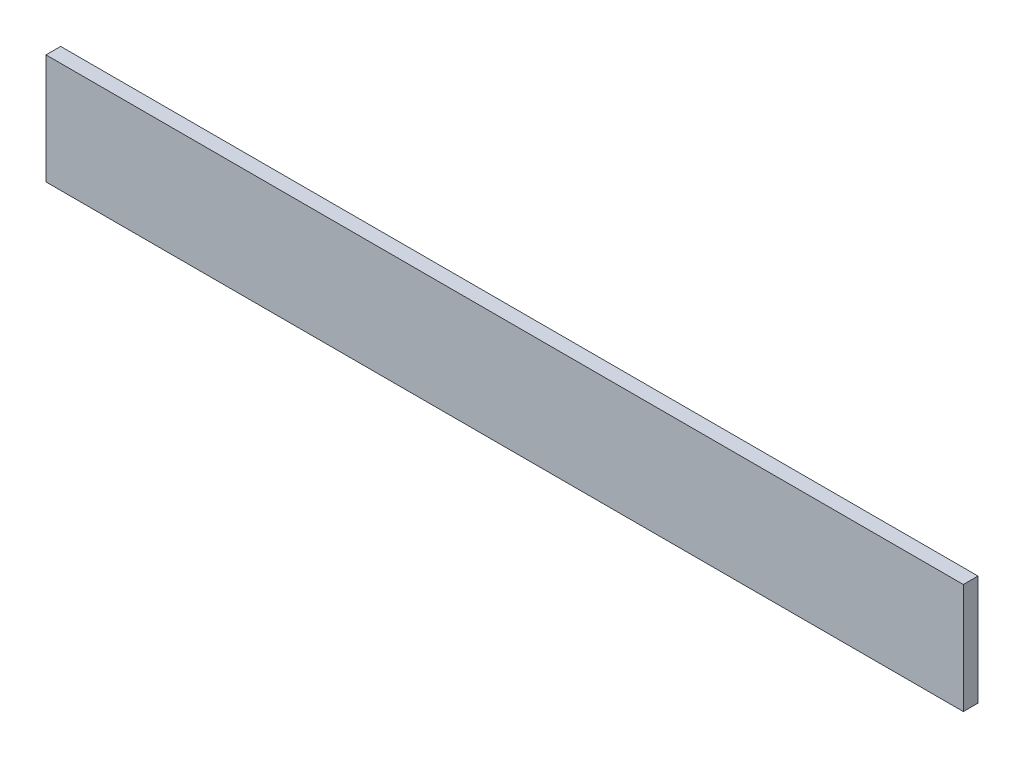
from build123d import *

# Parameters (mm, degrees)
SKETCH1_W           = 500
SKETCH1_H           = 60
BOSS_EXTRUDE1_DEPTH = 4


with BuildPart() as part:
    # Sketch1 → Boss-Extrude1 (new body, symmetric)
    with BuildSketch(Plane.XY):
        Rectangle(SKETCH1_W, SKETCH1_H)
    extrude(amount=BOSS_EXTRUDE1_DEPTH, both=True)


solid = part.part
